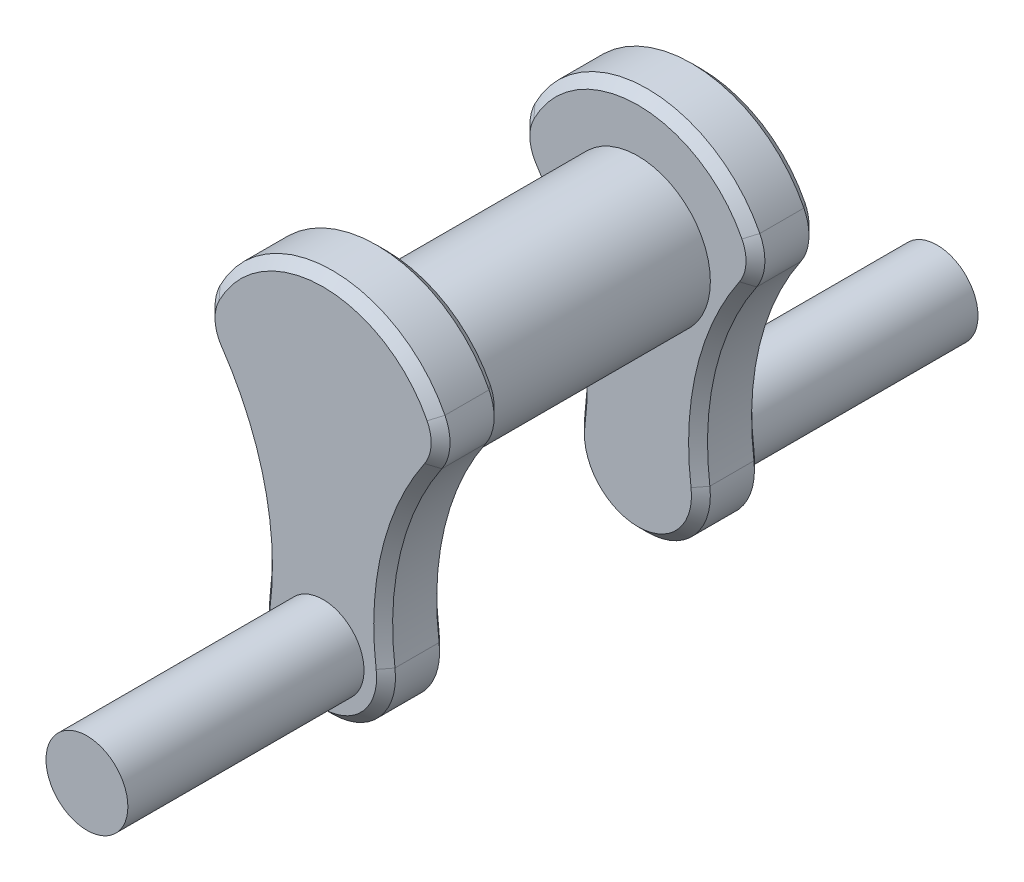
from build123d import *

# Parameters (mm, degrees)
SKETCH1_R                = 23
BOSS_EXTRUDE1_DEPTH      = 40
BOSS_EXTRUDE2_DEPTH      = 20
SKETCH3_R                = 13
BOSS_EXTRUDE3_DEPTH      = 75
FILLET1_R                = 15
CHAMFER2_SIZE            = 3
FILLET1_OF_MIRROR1_R     = 15
CHAMFER2_OF_MIRROR1_SIZE = 3


with BuildPart() as part:
    # Sketch1 → Boss-Extrude1 (new body, symmetric)
    with BuildSketch(Plane.XY):
        Circle(SKETCH1_R)
    extrude(amount=BOSS_EXTRUDE1_DEPTH, both=True)

    # Sketch2 → Boss-Extrude2 (add)
    with BuildSketch(Plane.XY.offset(40)):
        with BuildLine():
            ThreePointArc((39.051840285, 8.657584558), (0, 40), (-39.051840285, 8.657584558))
            ThreePointArc((-39.051840285, 8.657584558), (-22.47215166, -23.418781152), (-19.834213041, -59.430176458))
            ThreePointArc((-19.834213041, -59.430176458), (0, -82), (19.834213041, -59.430176458))
            ThreePointArc((19.834213041, -59.430176458), (22.47215166, -23.418781152), (39.051840285, 8.657584558))
        make_face()
    boss_extrude2 = extrude(amount=BOSS_EXTRUDE2_DEPTH)

    # Sketch3 → Boss-Extrude3 (add)
    with BuildSketch(Plane.XY.offset(60)):
        with Locations(Location((0, -62, 0), (0, 0, 180))):  # turned: the seam where the file's is
            Circle(SKETCH3_R)
    boss_extrude3 = extrude(amount=BOSS_EXTRUDE3_DEPTH)

    # Fillet1
    fillet1_edges = [part.edges().sort_by_distance(p)[0] for p in [
        (-39.051840285, 8.657584558, 50),
        (39.051840285, 8.657584558, 50),
    ]]
    fillet(fillet1_edges, radius=FILLET1_R)

    # Chamfer2
    chamfer2_edges = [part.edges().sort_by_distance(p)[0] for p in [
        (-21.554755506, -26.939885243, 40),
        (-21.554755506, -26.939885243, 60),
        (0, 40, 40),
        (37.287308792, 10.281927657, 40),
        (-37.287308792, 10.281927657, 40),
        (0, 40, 60),
        (37.287308792, 10.281927657, 60),
        (-37.287308792, 10.281927657, 60),
        (0, -82, 40),
        (21.554755506, -26.939885243, 40),
        (0, -82, 60),
        (21.554755506, -26.939885243, 60),
    ]]
    chamfer(chamfer2_edges, length=CHAMFER2_SIZE)

    # Mirror1: Boss-Extrude2, Boss-Extrude3 across plane
    add(boss_extrude2.mirror(Plane.XY))
    add(boss_extrude3.mirror(Plane.XY))

    # Fillet1 of Mirror1
    fillet1_of_mirror1_edges = [part.edges().sort_by_distance(p)[0] for p in [
        (-39.051840285, 8.657584558, -50),
        (39.051840285, 8.657584558, -50),
    ]]
    fillet(fillet1_of_mirror1_edges, radius=FILLET1_OF_MIRROR1_R)

    # Chamfer2 of Mirror1
    chamfer2_of_mirror1_edges = [part.edges().sort_by_distance(p)[0] for p in [
        (-21.554755506, -26.939885243, -40),
        (-21.554755506, -26.939885243, -60),
        (0, 40, -40),
        (37.287308792, 10.281927657, -40),
        (-37.287308792, 10.281927657, -40),
        (0, 40, -60),
        (37.287308792, 10.281927657, -60),
        (-37.287308792, 10.281927657, -60),
        (0, -82, -40),
        (21.554755506, -26.939885243, -40),
        (0, -82, -60),
        (21.554755506, -26.939885243, -60),
    ]]
    chamfer(chamfer2_of_mirror1_edges, length=CHAMFER2_OF_MIRROR1_SIZE)


solid = part.part
